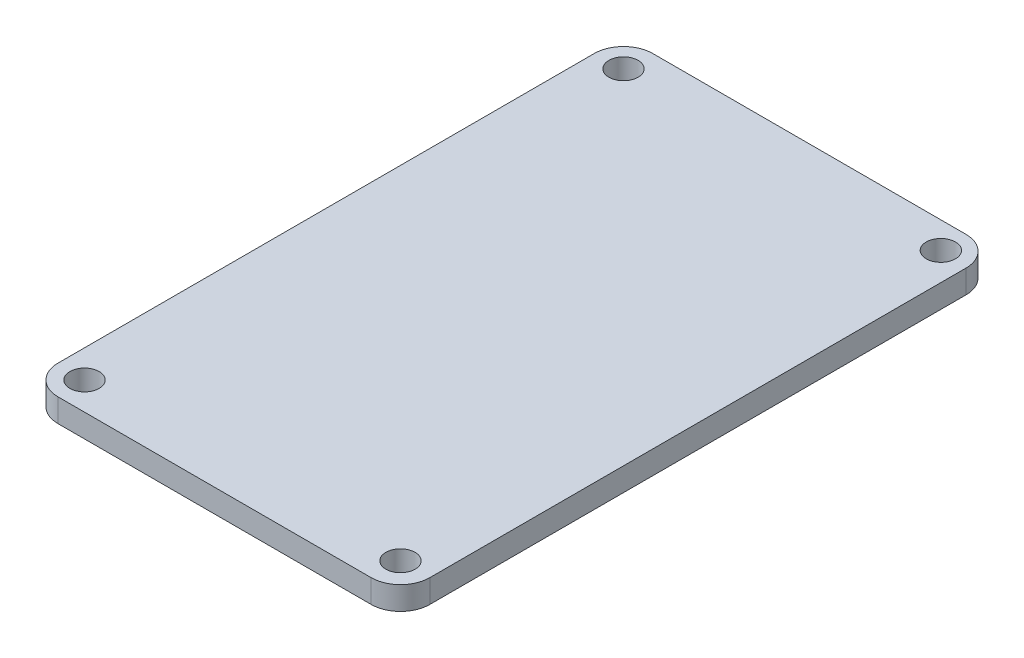
from build123d import *

# Parameters (mm, degrees)
BOSS_EXTRUDE1_DEPTH       = 1.5875
F_2_0MM_DOWEL_HOLE1_D     = 2
F_2_0MM_DOWEL_HOLE1_DEPTH = 38.1
F_2_0MM_DOWEL_HOLE1_TIP   = 0.600860619


with BuildPart() as part:
    # Sketch1 → Boss-Extrude1 (new body)
    with BuildSketch(Plane(origin=(0, 0, 0), x_dir=(1, 0, 0), z_dir=(0, 1, 0))):
        with BuildLine():
            Line((-10.7, -20.32), (10.7, -20.32))
            ThreePointArc((10.7, -20.32), (12.114213562, -19.734213562), (12.7, -18.32))
            Line((12.7, -18.32), (12.7, 18.32))
            ThreePointArc((12.7, 18.32), (12.114213562, 19.734213562), (10.7, 20.32))
            Line((10.7, 20.32), (-10.7, 20.32))
            ThreePointArc((-10.7, 20.32), (-12.114213562, 19.734213562), (-12.7, 18.32))
            Line((-12.7, 18.32), (-12.7, -18.32))
            ThreePointArc((-12.7, -18.32), (-12.114213562, -19.734213562), (-10.7, -20.32))
        make_face()
    extrude(amount=BOSS_EXTRUDE1_DEPTH)

    # Ø2.0mm Dowel Hole1
    with Locations(Plane(origin=(0, 1.5875, 0), x_dir=(1, 0, 0), z_dir=(0, 1, 0))):
        with Locations((-10.79479099, 18.415), (10.795, 18.51), (10.7, -18.32), (-10.79479099, -18.415)):
            Hole(F_2_0MM_DOWEL_HOLE1_D / 2, depth=F_2_0MM_DOWEL_HOLE1_DEPTH)
            with Locations((0, 0, -(F_2_0MM_DOWEL_HOLE1_DEPTH + F_2_0MM_DOWEL_HOLE1_TIP / 2))):  # 118° drill point
                Cone(0, F_2_0MM_DOWEL_HOLE1_D / 2, F_2_0MM_DOWEL_HOLE1_TIP, mode=Mode.SUBTRACT)


solid = part.part
